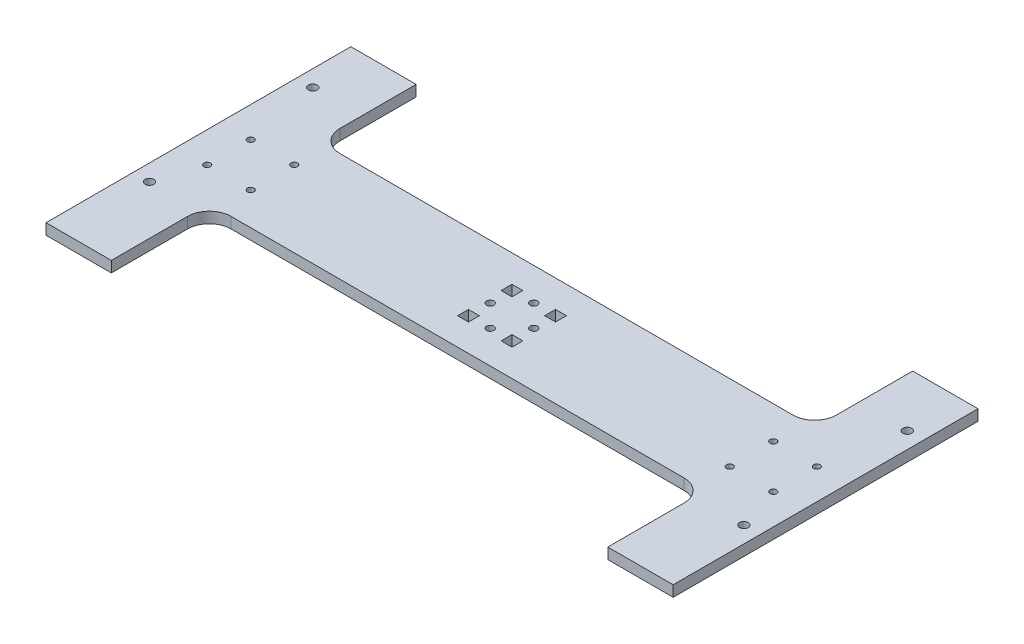
from build123d import *

# Parameters (mm, degrees)
SKETCH1_W           = 288
SKETCH1_H           = 50
BOSS_EXTRUDE1_DEPTH = 5
SKETCH2_R           = 1.5
CUT_EXTRUDE1_DEPTH  = 5
SKETCH3_W           = 30
SKETCH3_H           = 45
BOSS_EXTRUDE2_DEPTH = 5
FILLET1_R           = 10
SKETCH4_W           = 5
SKETCH4_H           = 5
CUT_EXTRUDE2_DEPTH  = 5
SKETCH5_R           = 1.7
CUT_EXTRUDE3_DEPTH  = 5
SKETCH7_R           = 2
CUT_EXTRUDE4_DEPTH  = 10


with BuildPart() as part:
    # Sketch1 → Boss-Extrude1 (new body)
    with BuildSketch(Plane(origin=(0, 0, 0), x_dir=(1, 0, 0), z_dir=(0, 1, 0))):
        Rectangle(SKETCH1_W, SKETCH1_H)
    extrude(amount=BOSS_EXTRUDE1_DEPTH)

    # Sketch2 → Cut-Extrude1 (cut)
    with BuildSketch(Plane(origin=(0, 5, 0), x_dir=(1, 0, 0), z_dir=(0, 1, 0))):
        with Locations((-130, 10)):
            Circle(SKETCH2_R)
        with Locations((-110, 10)):
            Circle(SKETCH2_R)
        with Locations((-110, -10)):
            Circle(SKETCH2_R)
        with Locations((-130, -10)):
            Circle(SKETCH2_R)
        with Locations((130, -10)):
            Circle(SKETCH2_R)
        with Locations((110, -10)):
            Circle(SKETCH2_R)
        with Locations((110, 10)):
            Circle(SKETCH2_R)
        with Locations((130, 10)):
            Circle(SKETCH2_R)
    extrude(amount=-CUT_EXTRUDE1_DEPTH, mode=Mode.SUBTRACT)

    # Sketch3 → Boss-Extrude2 (add)
    with BuildSketch(Plane(origin=(0, 5, 0), x_dir=(1, 0, 0), z_dir=(0, 1, 0))):
        with Locations((-129, 47.5)):
            Rectangle(SKETCH3_W, SKETCH3_H)
        with Locations((-129, -47.5)):
            Rectangle(SKETCH3_W, SKETCH3_H)
        with Locations((129, -47.5)):
            Rectangle(SKETCH3_W, SKETCH3_H)
        with Locations((129, 47.5)):
            Rectangle(SKETCH3_W, SKETCH3_H)
    extrude(amount=-BOSS_EXTRUDE2_DEPTH)

    # Fillet1
    fillet1_edges = [part.edges().sort_by_distance(p)[0] for p in [
        (-114, 2.5, -25),
        (-114, 2.5, 25),
        (114, 2.5, 25),
        (114, 2.5, -25),
    ]]
    fillet(fillet1_edges, radius=FILLET1_R)

    # Sketch4 → Cut-Extrude2 (cut)
    with BuildSketch(Plane(origin=(0, 5, 0), x_dir=(1, 0, 0), z_dir=(0, 1, 0))):
        with Locations((10, 10)):
            Rectangle(SKETCH4_W, SKETCH4_H)
        with Locations((-10, 10)):
            Rectangle(SKETCH4_W, SKETCH4_H)
        with Locations((-10, -10)):
            Rectangle(SKETCH4_W, SKETCH4_H)
        with Locations((10, -10)):
            Rectangle(SKETCH4_W, SKETCH4_H)
    extrude(amount=-CUT_EXTRUDE2_DEPTH, mode=Mode.SUBTRACT)

    # Sketch5 → Cut-Extrude3 (cut)
    with BuildSketch(Plane(origin=(0, 5, 0), x_dir=(1, 0, 0), z_dir=(0, 1, 0))):
        with Locations((0, 10)):
            Circle(SKETCH5_R)
        with Locations((0, -10)):
            Circle(SKETCH5_R)
        with Locations((10, 0)):
            Circle(SKETCH5_R)
        with Locations((-10, 0)):
            Circle(SKETCH5_R)
    extrude(amount=-CUT_EXTRUDE3_DEPTH, mode=Mode.SUBTRACT)

    # Sketch7 → Cut-Extrude4 (cut)
    with BuildSketch(Plane(origin=(0, 5, 0), x_dir=(1, 0, 0), z_dir=(0, 1, 0))):
        with Locations((-136.5, 45)):
            Circle(SKETCH7_R)
        with Locations((-136.5, -30)):
            Circle(SKETCH7_R)
        with Locations((136.5, -30)):
            Circle(SKETCH7_R)
        with Locations((136.5, 45)):
            Circle(SKETCH7_R)
    extrude(amount=-CUT_EXTRUDE4_DEPTH, mode=Mode.SUBTRACT)


solid = part.part
